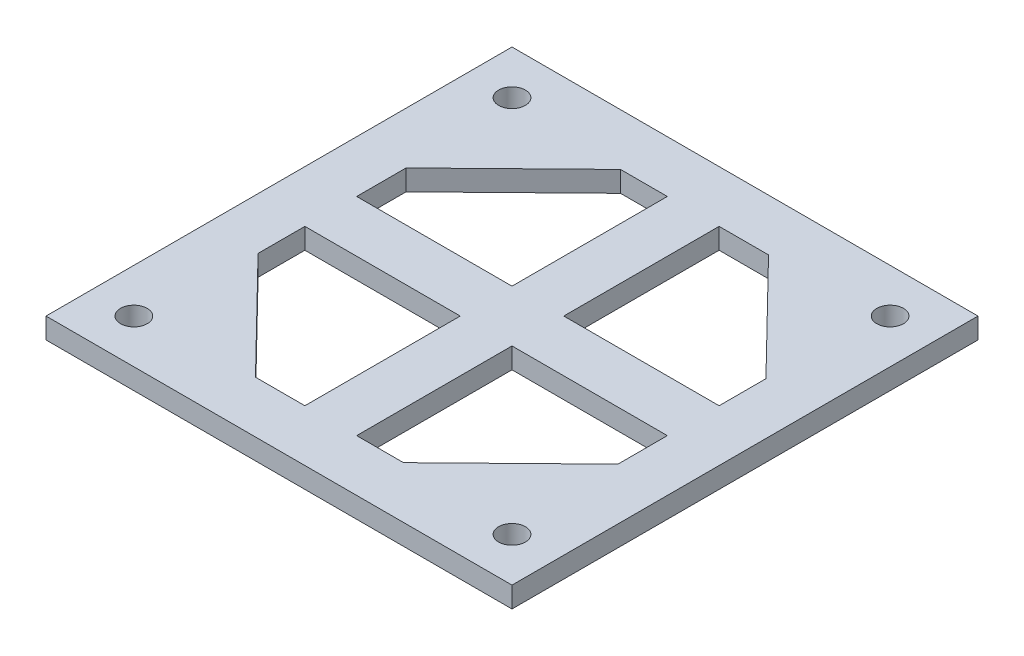
from build123d import *

# Parameters (mm, degrees)
SKETCH2_W           = 45
SKETCH2_H           = 45
BOSS_EXTRUDE1_DEPTH = 2
CUT_EXTRUDE1_DEPTH  = 2
SKETCH7_R           = 1.289214756
CUT_EXTRUDE2_DEPTH  = 2
CIRPATTERN1_COUNT   = 4


with BuildPart() as part:
    # Sketch2 → Boss-Extrude1 (new body)
    with BuildSketch(Plane(origin=(0, 0, 0), x_dir=(1, 0, 0), z_dir=(0, 1, 0))):
        Rectangle(SKETCH2_W, SKETCH2_H)
    extrude(amount=BOSS_EXTRUDE1_DEPTH)

    # Sketch4 → Cut-Extrude1 (cut)
    with BuildSketch(Plane.XZ):
        Polygon((7.021849723, 17.5), (17.5, 7.271715562), (17.5, 2.5), (2.5, 2.5), (2.5, 17.5), align=None)
    cut_extrude1 = extrude(amount=-CUT_EXTRUDE1_DEPTH, mode=Mode.SUBTRACT)

    # Sketch7 → Cut-Extrude2 (cut)
    with BuildSketch(Plane.XZ):
        with Locations((18.257359313, 18.257359313)):
            Circle(SKETCH7_R)
    cut_extrude2 = extrude(amount=-CUT_EXTRUDE2_DEPTH, mode=Mode.SUBTRACT)

    # CirPattern1: Cut-Extrude1, Cut-Extrude2 ×4 about axis
    cirpattern1_axis = Axis((0, 0, 0), (0, 1, 0))
    for i in range(1, CIRPATTERN1_COUNT):
        add(cut_extrude1.rotate(cirpattern1_axis, i * 360 / CIRPATTERN1_COUNT), mode=Mode.SUBTRACT)
        add(cut_extrude2.rotate(cirpattern1_axis, i * 360 / CIRPATTERN1_COUNT), mode=Mode.SUBTRACT)


solid = part.part
